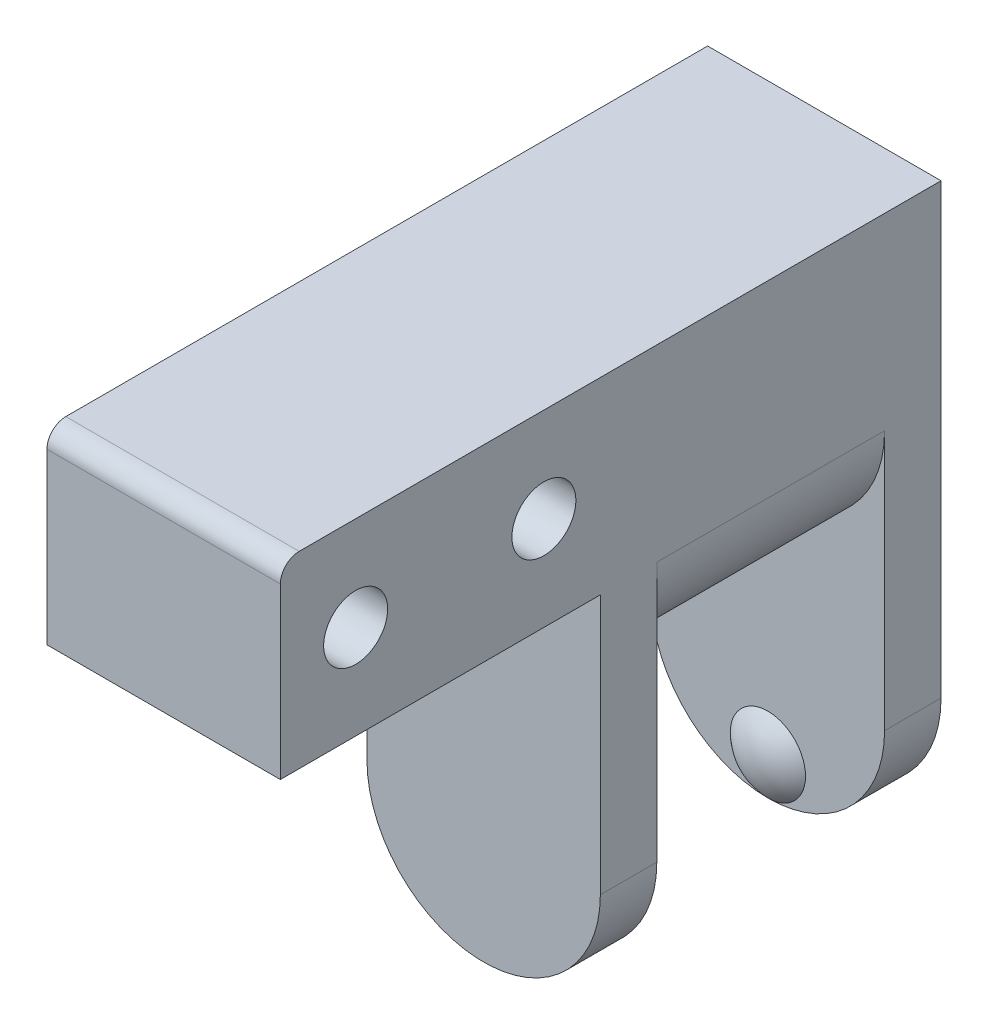
from build123d import *

# Parameters (mm, degrees)
EXTRUDE_1_DEPTH          = 12.4
CUT_EXTRUDE_1_DEPTH      = 12.1
CUT_EXTRUDE_2_DEPTH      = 21
CUT_EXTRUDE_2_DEPTH_BACK = 16.1
HOLE_WIZARD_M32_D        = 3.4
HOLE_WIZARD_M32_DEPTH    = 15
HOLE_WIZARD_M32_TIP      = 1.021463052
FILLET_2_R               = 1


with BuildPart() as part:
    # Эскиз2 → Бобышка-Вытянуть1 (new body)
    with BuildSketch(Plane(origin=(0, 0, 0), x_dir=(0, 0, -1), z_dir=(1, 0, 0))):
        Polygon((12.1, -8), (12.1, -20), (15.1, -20), (15.1, 10), (-20, 10), (-20, 0), (-3, 0), (-3, -20), (0, -20), (0, -8), align=None)
    extrude(amount=EXTRUDE_1_DEPTH)

    # Эскиз3 → Вырез-Вытянуть1 (cut)
    with BuildSketch(Plane.XY):
        with BuildLine():
            Line((0, 0), (-4.310236897, 0))
            Line((-4.310236897, 0), (-4.310236897, -10.158248203))
            Line((-4.310236897, -10.158248203), (16.784307367, -10.158248203))
            Line((16.784307367, -10.158248203), (16.784307367, 0))
            Line((16.784307367, 0), (12.4, 0))
            ThreePointArc((12.4, 0), (6.2, -6.2), (0, 0))
        make_face()
    extrude(amount=-CUT_EXTRUDE_1_DEPTH, mode=Mode.SUBTRACT)

    # Эскиз4 → Вырез-Вытянуть2 (cut, two sides)
    with BuildSketch(Plane.XY) as cut_extrude_2_sk:
        with BuildLine():
            Line((0, -13.8), (-4.529189241, -13.8))
            Line((-4.529189241, -13.8), (-4.529189241, -23.032738442))
            Line((-4.529189241, -23.032738442), (17.457291493, -23.032738442))
            Line((17.457291493, -23.032738442), (17.457291493, -13.8))
            Line((17.457291493, -13.8), (12.4, -13.8))
            ThreePointArc((12.4, -13.8), (6.2, -20), (0, -13.8))
        make_face()
    extrude(amount=CUT_EXTRUDE_2_DEPTH, mode=Mode.SUBTRACT)
    extrude(cut_extrude_2_sk.sketch, amount=-CUT_EXTRUDE_2_DEPTH_BACK, mode=Mode.SUBTRACT)

    # Отверстие с зазором M32
    with Locations(Plane(origin=(12.4, 0, 0), x_dir=(0, 0, -1), z_dir=(1, 0, 0))):
        with Locations((-6, 5), (-16, 5)):
            Hole(HOLE_WIZARD_M32_D / 2, depth=HOLE_WIZARD_M32_DEPTH)
            with Locations((0, 0, -(HOLE_WIZARD_M32_DEPTH + HOLE_WIZARD_M32_TIP / 2))):  # 118° drill point
                Cone(0, HOLE_WIZARD_M32_D / 2, HOLE_WIZARD_M32_TIP, mode=Mode.SUBTRACT)

    # Эскиз12 → Повернуть1 (revolve)
    with BuildSketch(Plane(origin=(6.2, 0, 0), x_dir=(0, 0, -1), z_dir=(1, 0, 0))):
        with BuildLine():
            Line((12.1, -20), (12.1, -18))
            Line((12.1, -18), (11.3, -18))
            ThreePointArc((11.3, -18), (11.507417596, -19.077032961), (12.1, -20))
        make_face()
    revolve(axis=Axis((6.2, -18, -11.3), (0, 0, -1)))

    # Скругление2
    fillet_2_edges = [part.edges().sort_by_distance(p)[0] for p in [
        (6.2, 10, 20),
    ]]
    fillet(fillet_2_edges, radius=FILLET_2_R)


solid = part.part
